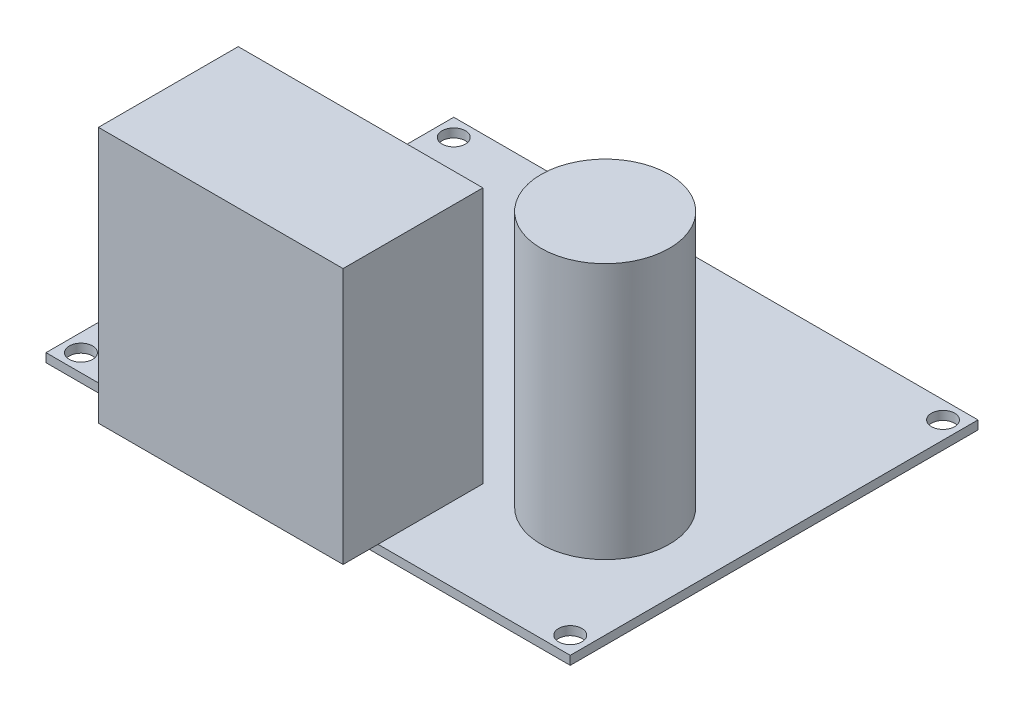
from build123d import *

# Parameters (mm, degrees)
ESBO_O1_W                = 90
ESBO_O1_H                = 70
RESSALTO_EXTRUS_O1_DEPTH = 1.5
ESBO_O2_R                = 2
CORTE_EXTRUS_O1_DEPTH    = 1.5
ESBO_O3_R                = 11
RESSALTO_EXTRUS_O2_DEPTH = 44


with BuildPart() as part:
    # Esboço1 → Ressalto-extrusão1 (new body)
    with BuildSketch(Plane(origin=(0, 0, 0), x_dir=(1, 0, 0), z_dir=(0, 1, 0))):
        with Locations((45, 35)):
            Rectangle(ESBO_O1_W, ESBO_O1_H)
    extrude(amount=RESSALTO_EXTRUS_O1_DEPTH)

    # Esboço2 → Corte-extrusão1 (cut)
    with BuildSketch(Plane(origin=(0, 1.5, 0), x_dir=(1, 0, 0), z_dir=(0, 1, 0))):
        with Locations((87, 3)):
            Circle(ESBO_O2_R)
        with Locations((87, 67)):
            Circle(ESBO_O2_R)
        with Locations((3, 3)):
            Circle(ESBO_O2_R)
        with Locations((3, 67)):
            Circle(ESBO_O2_R)
    extrude(amount=-CORTE_EXTRUS_O1_DEPTH, mode=Mode.SUBTRACT)

    # Esboço3 → Ressalto-extrusão2 (add)
    with BuildSketch(Plane(origin=(0, 1.5, 0), x_dir=(1, 0, 0), z_dir=(0, 1, 0))):
        with Locations((71, 25)):
            Circle(ESBO_O3_R)
        Polygon((15, 0), (15, -6), (57, -6), (57, 0), (57, 18), (15, 18), align=None)
    extrude(amount=RESSALTO_EXTRUS_O2_DEPTH)


solid = part.part
